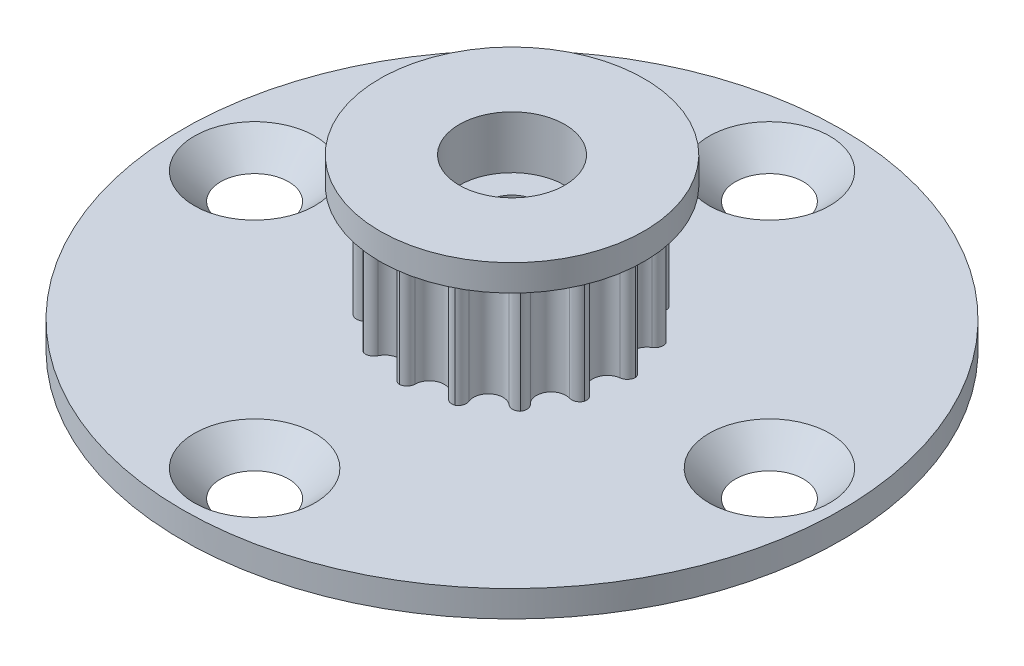
from build123d import *

# Parameters (mm, degrees)
BOSS_EXTRUDE1_DEPTH     = 3.556
CIRPATTERN1_COUNT       = 15
SKETCH2_W               = 7.954934775
SKETCH2_H               = 1.5875
SKETCH9_R               = 19.84375
SKETCH9_R_2             = 1.5
BOSS_EXTRUDE2_DEPTH     = 1.5875
SKETCH3_R               = 1.74625
CUT_EXTRUDE1_DEPTH      = 6.087499985
CUT_EXTRUDE1_DEPTH_BACK = 6.087499985
CIRPATTERN2_COUNT       = 4
SKETCH12_R              = 3.175
CUT_EXTRUDE2_DEPTH      = 3.175
SKETCH13_R              = 1.525
CUT_EXTRUDE4_DEPTH      = 7.99999997


with BuildPart() as part:
    # Sketch1 → Boss-Extrude1 (new body, symmetric)
    with BuildSketch(Plane(origin=(0, 0, 0), x_dir=(1, 0, 0), z_dir=(0, 1, 0))):
        with BuildLine():
            ThreePointArc((0.866466766, 6.246873729), (0.552789859, 5.752672402), (0, 5.560184675))
            ThreePointArc((0, 5.560184675), (-1.156027397, -5.438681299), (2.261530849, 5.079481453))
            ThreePointArc((2.261530849, 5.079481453), (1.834823997, 5.480167634), (1.749275672, 6.059226903))
            ThreePointArc((1.749275672, 6.059226903), (1.687548707, 6.408986287), (1.409147818, 6.629519254))
            ThreePointArc((1.409147818, 6.629519254), (1.065117112, 6.541288206), (0.866466766, 6.246873729))
        make_face()
    boss_extrude1 = extrude(amount=BOSS_EXTRUDE1_DEPTH, both=True)

    # CirPattern1: Boss-Extrude1 ×15 about axis
    cirpattern1_axis = Axis((0, 0, 0), (0, 1, 0))
    for i in range(1, CIRPATTERN1_COUNT):
        add(boss_extrude1.rotate(cirpattern1_axis, i * 360 / CIRPATTERN1_COUNT))

    # Sketch2 → Revolve3 (revolve)
    with BuildSketch(Plane(origin=(0, 0, 0), x_dir=(0, 0, -1), z_dir=(1, 0, 0))):
        with Locations((3.977467388, 4.293749985)):
            Rectangle(SKETCH2_W, SKETCH2_H)
    revolve3 = revolve(axis=Axis((0, 3.3, 0), (0, -1, 0)))

    # Mirror1: Revolve3 across plane
    add(revolve3.mirror(Plane.ZX))

    # Sketch9 → Boss-Extrude2 (add)
    with BuildSketch(Plane.XZ.offset(5.087499985)):
        Circle(SKETCH9_R)
        Circle(SKETCH9_R_2, mode=Mode.SUBTRACT)
    extrude(amount=-BOSS_EXTRUDE2_DEPTH)

    # Sketch3 → Cut-Extrude1 (cut, two sides)
    with BuildSketch(Plane(origin=(0, 0, 0), x_dir=(1, 0, 0), z_dir=(0, 1, 0))) as cut_extrude1_sk:
        with Locations((-15.5, 0)):
            Circle(SKETCH3_R)
        with Locations((0, 15.5)):
            Circle(SKETCH3_R)
        with Locations((15.5, 0)):
            Circle(SKETCH3_R)
        with Locations((0, -15.5)):
            Circle(SKETCH3_R)
    extrude(amount=CUT_EXTRUDE1_DEPTH, mode=Mode.SUBTRACT)
    extrude(cut_extrude1_sk.sketch, amount=-CUT_EXTRUDE1_DEPTH_BACK, mode=Mode.SUBTRACT)

    # Sketch6 → Cut-Revolve2 (revolve, cut)
    with BuildSketch(Plane.XY):
        Polygon((-11.8678, -3.499999985), (-15.5, -7.132199985), (-15.5, -3.499999985), align=None)
    cut_revolve2 = revolve(axis=Axis((-15.5, -5.087499985, 0), (0, 1, 0)), mode=Mode.SUBTRACT)

    # CirPattern2: Cut-Revolve2 ×4 about axis
    cirpattern2_axis = Axis((0, 0, 0), (0, 1, 0))
    for i in range(1, CIRPATTERN2_COUNT):
        add(cut_revolve2.rotate(cirpattern2_axis, i * 360 / CIRPATTERN2_COUNT), mode=Mode.SUBTRACT)

    # Sketch12 → Cut-Extrude2 (cut)
    with BuildSketch(Plane(origin=(0, 5.087499985, 0), x_dir=(1, 0, 0), z_dir=(0, 1, 0))):
        Circle(SKETCH12_R)
    extrude(amount=-CUT_EXTRUDE2_DEPTH, mode=Mode.SUBTRACT)

    # Sketch13 → Cut-Extrude4 (cut, through all)
    with BuildSketch(Plane(origin=(0, 1.912499985, 0), x_dir=(1, 0, 0), z_dir=(0, 1, 0))):
        Circle(SKETCH13_R)
    extrude(amount=-CUT_EXTRUDE4_DEPTH, mode=Mode.SUBTRACT)


solid = part.part
